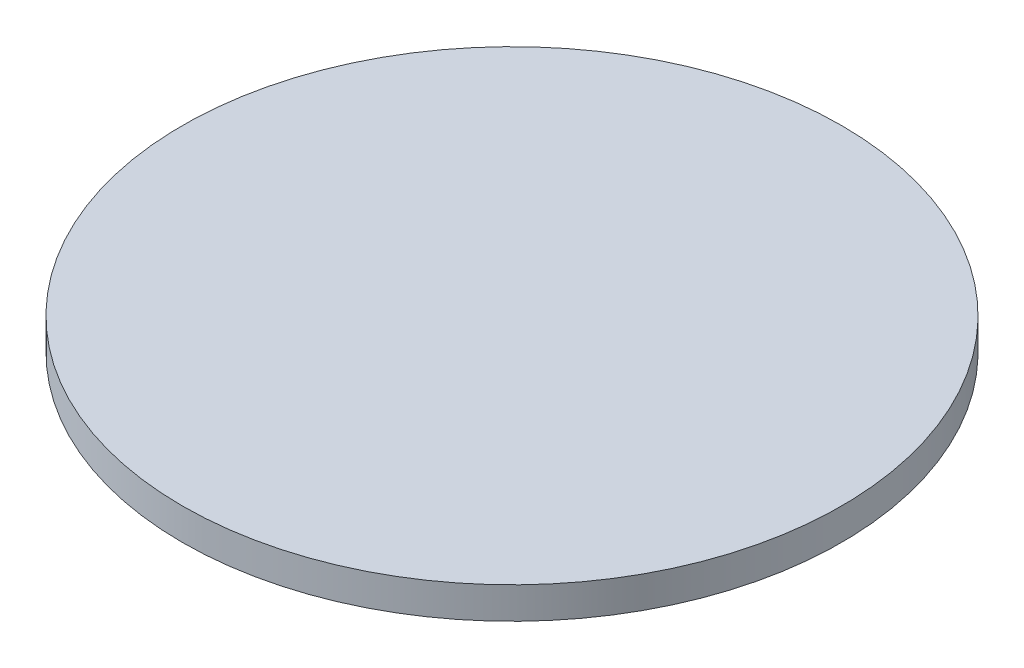
from build123d import *

# Parameters (mm, degrees)
SKETCH1_R           = 33.0835
BOSS_EXTRUDE1_DEPTH = 3.175


with BuildPart() as part:
    # Sketch1 → Boss-Extrude1 (new body)
    with BuildSketch(Plane(origin=(0, 0, 0), x_dir=(1, 0, 0), z_dir=(0, 1, 0))):
        Circle(SKETCH1_R)
    extrude(amount=BOSS_EXTRUDE1_DEPTH)


solid = part.part
